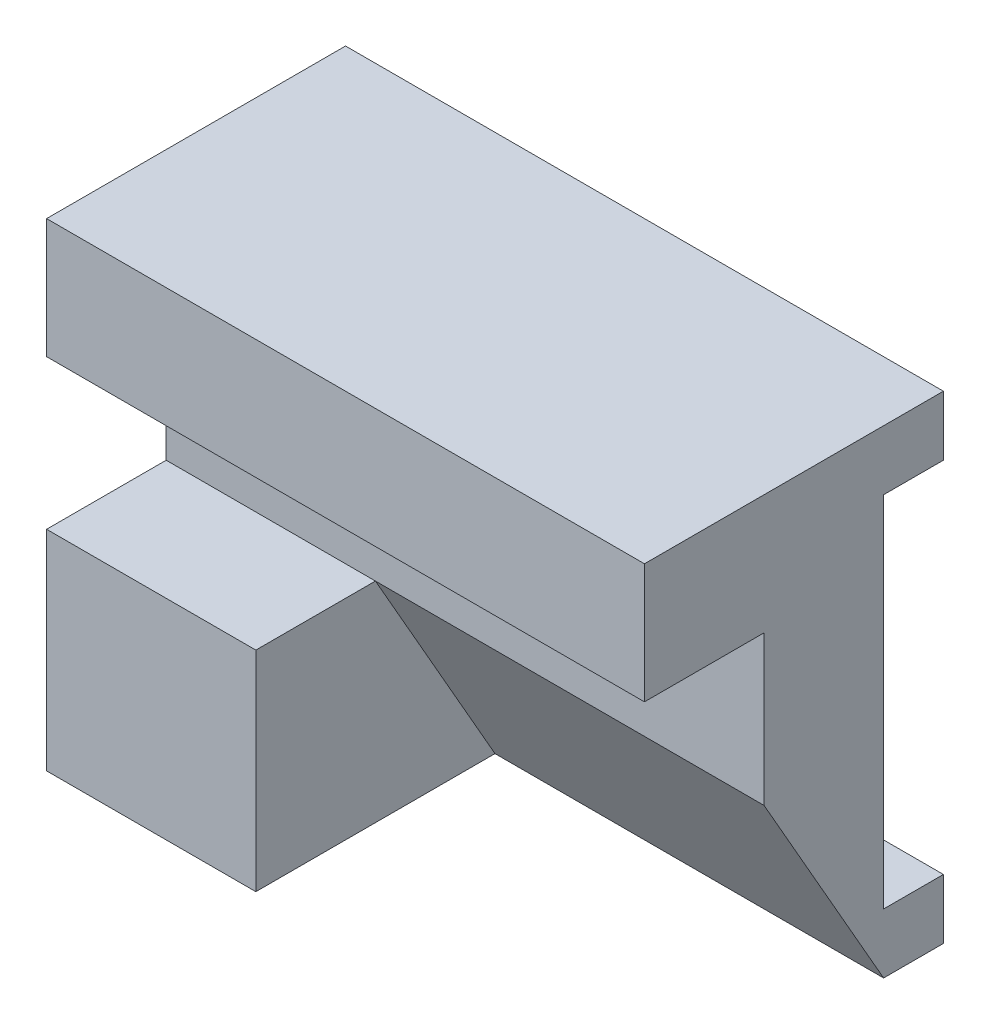
from build123d import *

# Parameters (mm, degrees)
SKETCH1_R           = 6
SKETCH1_W           = 65
SKETCH1_H           = 35
BOSS_EXTRUDE1_DEPTH = 20
SKETCH1_3_W         = 35
SKETCH1_3_H         = 35
SKETCH1_3_W_2       = 100
SKETCH1_3_H_2       = 20
BOSS_EXTRUDE2_DEPTH = 40
SKETCH3_W           = 10
SKETCH3_H           = 10
BOSS_EXTRUDE4_DEPTH = 100
CUT_EXTRUDE1_DEPTH  = 65


with BuildPart() as part:
    # Sketch1 → Boss-Extrude1 (new body)
    with BuildSketch(Plane.XY):
        Polygon((100, -20), (0, -20), (0, -45), (35, -45), (100, -45), align=None)
        with Locations((15, -32.5)):
            Circle(SKETCH1_R, mode=Mode.SUBTRACT)
        with Locations((75, -32.5)):
            Circle(SKETCH1_R, mode=Mode.SUBTRACT)
        with Locations((67.5, -62.5)):
            Rectangle(SKETCH1_W, SKETCH1_H)
    extrude(amount=BOSS_EXTRUDE1_DEPTH)

    # Sketch1_3 → Boss-Extrude2 (add)
    with BuildSketch(Plane.XY):
        with Locations((17.5, -62.5)):
            Rectangle(SKETCH1_3_W, SKETCH1_3_H)
        with Locations((50, -10)):
            Rectangle(SKETCH1_3_W_2, SKETCH1_3_H_2)
    extrude(amount=BOSS_EXTRUDE2_DEPTH)

    # Sketch3 → Boss-Extrude4 (add)
    with BuildSketch(Plane(origin=(0, 0, 0), x_dir=(0, 0, -1), z_dir=(1, 0, 0))):
        with Locations((5, -75)):
            Rectangle(SKETCH3_W, SKETCH3_H)
        with Locations((5, -5)):
            Rectangle(SKETCH3_W, SKETCH3_H)
    extrude(amount=BOSS_EXTRUDE4_DEPTH)

    # Sketch4 → Cut-Extrude1 (cut)
    with BuildSketch(Plane(origin=(100, 0, 0), x_dir=(0, 0, -1), z_dir=(1, 0, 0))):
        Polygon((-20, -45), (0, -80), (-20, -80), align=None)
    extrude(amount=-CUT_EXTRUDE1_DEPTH, mode=Mode.SUBTRACT)


solid = part.part
